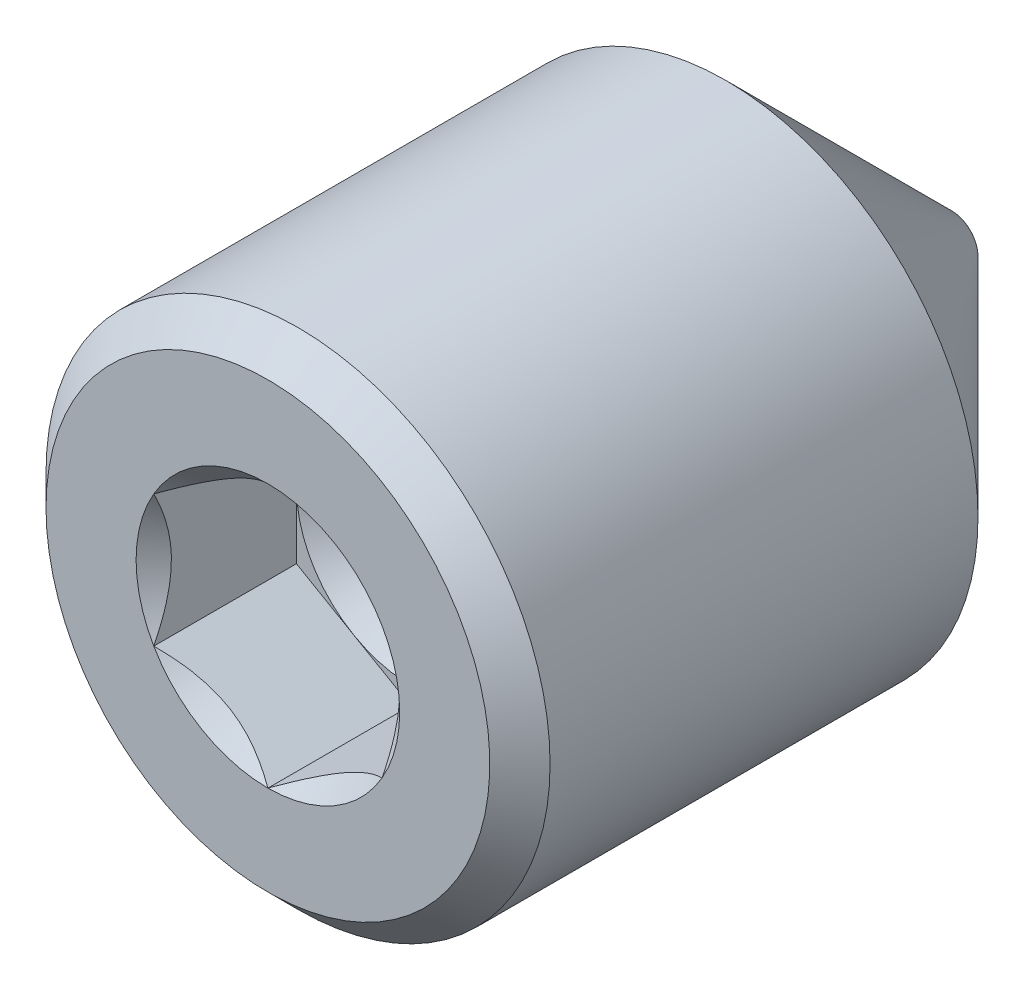
from build123d import *

# Parameters (mm, degrees)
CHAMFER1_SIZE      = 0.20955
CUT_EXTRUDE1_DEPTH = 0.9921875
FILLET1_R          = 0.035052


with BuildPart() as part:
    # Sketch2 → Revolve1 (revolve)
    with BuildSketch(Plane(origin=(0, 0, 0), x_dir=(0, 0, -1), z_dir=(1, 0, 0))):
        Polygon((-2.38125, 0), (2.38125, 0), (2.38125, 0.17526), (0.80391, 1.7526), (-2.38125, 1.7526), align=None)
    revolve(axis=Axis((0, 0, 2.38125), (0, 0, -1)))

    # Chamfer1
    chamfer1_edges = [part.edges().sort_by_distance(p)[0] for p in [
        (0, -1.7526, 2.38125),
    ]]
    chamfer(chamfer1_edges, length=CHAMFER1_SIZE)

    # Sketch3 → Cut-Extrude1 (cut)
    with BuildSketch(Plane.XY.offset(2.38125)):
        Polygon((0, -0.916543552), (0.79375, -0.458271776), (0.79375, 0.458271776), (0, 0.916543552), (-0.79375, 0.458271776), (-0.79375, -0.458271776), align=None)
    extrude(amount=-CUT_EXTRUDE1_DEPTH, mode=Mode.SUBTRACT)

    # Cut-Extrude2 cone 1 section (through the dimple's axis) → Cut-Extrude2 (revolve, cut)
    with BuildSketch(Plane(origin=(0, 0, 2.38125), x_dir=(0, -1, 0), z_dir=(1, 0, 0))):
        Polygon((0, 0), (0.916543552, 0), (0, 0.916543552), align=None)
    revolve(axis=Axis((0, 0, 2.38125), (0, 0, -1)), mode=Mode.SUBTRACT)

    # Cut-Extrude3 cone 1 section (through the dimple's axis) → Cut-Extrude3 (revolve, cut)
    with BuildSketch(Plane(origin=(0, 0, 1.3890625), x_dir=(0, -1, 0), z_dir=(1, 0, 0))):
        Polygon((0, 0), (0.79375, 0), (0, 0.79375), align=None)
    revolve(axis=Axis((0, 0, 1.3890625), (0, 0, -1)), mode=Mode.SUBTRACT)

    # Fillet1
    fillet1_edges = [part.edges().sort_by_distance(p)[0] for p in [
        (0, -0.17526, -2.38125),
    ]]
    fillet(fillet1_edges, radius=FILLET1_R)


solid = part.part
